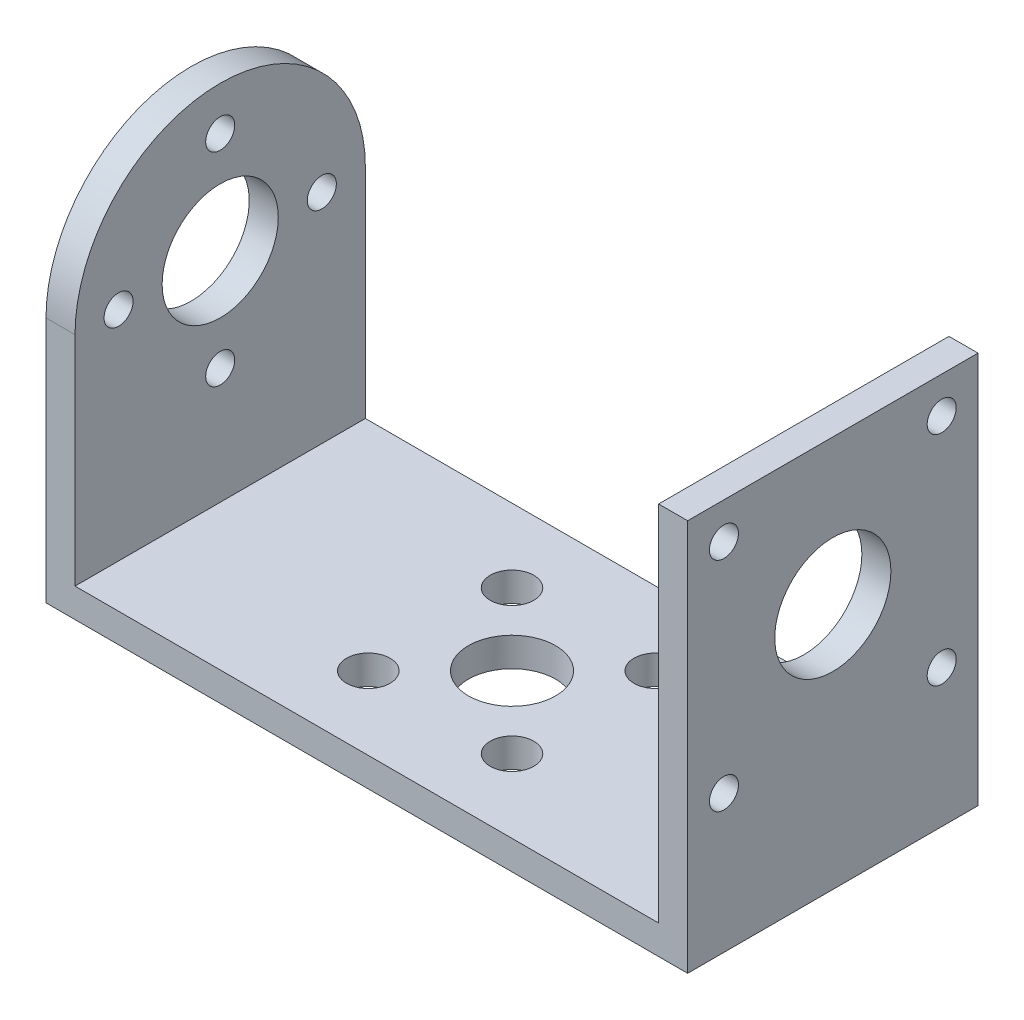
from build123d import *

# Parameters (mm, degrees)
SKETCH_1_W          = 44.2
SKETCH_1_H          = 20
EXTRUDE_1_DEPTH     = 2
CUT_EXTRUDE_1_REACH = 4
SKETCH_2_R          = 3
SKETCH_2_R_2        = 1.5
SKETCH_3_W          = 20
SKETCH_3_H          = 25
EXTRUDE_2_DEPTH     = 2
CUT_EXTRUDE_2_REACH = 46.2
SKETCH_4_R          = 4
SKETCH_4_R_2        = 1
CUT_EXTRUDE_3_REACH = 46.2
SKETCH_5_R          = 4
SKETCH_5_R_2        = 1


with BuildPart() as part:
    # 草图1 → 凸台-拉伸1 (new body)
    with BuildSketch(Plane(origin=(0, 0, 0), x_dir=(1, 0, 0), z_dir=(0, 1, 0))):
        Rectangle(SKETCH_1_W, SKETCH_1_H)
    extrude(amount=EXTRUDE_1_DEPTH)

    # 草图2 → 切除-拉伸1 (cut, up to next)
    with BuildSketch(Plane(origin=(0, 2, 0), x_dir=(1, 0, 0), z_dir=(0, 1, 0)), mode=Mode.PRIVATE) as cut_extrude_1_sk1:
        Circle(SKETCH_2_R)
    cut_extrude_1_tool1 = extrude(cut_extrude_1_sk1.sketch, amount=-CUT_EXTRUDE_1_REACH, mode=Mode.PRIVATE) & part.part
    add(cut_extrude_1_tool1.solids().sort_by_distance((0, 2, 0))[0], mode=Mode.SUBTRACT)
    # 草图2 → 切除-拉伸1 (cut, up to next)
    with BuildSketch(Plane(origin=(0, 2, 0), x_dir=(1, 0, 0), z_dir=(0, 1, 0)), mode=Mode.PRIVATE) as cut_extrude_1_sk2:
        with Locations((4.949747468, -4.949747468)):
            Circle(SKETCH_2_R_2)
    cut_extrude_1_tool2 = extrude(cut_extrude_1_sk2.sketch, amount=-CUT_EXTRUDE_1_REACH, mode=Mode.PRIVATE) & part.part
    add(cut_extrude_1_tool2.solids().sort_by_distance((4.949747, 2, 4.949747))[0], mode=Mode.SUBTRACT)
    # 草图2 → 切除-拉伸1 (cut, up to next)
    with BuildSketch(Plane(origin=(0, 2, 0), x_dir=(1, 0, 0), z_dir=(0, 1, 0)), mode=Mode.PRIVATE) as cut_extrude_1_sk3:
        with Locations((-4.949747468, -4.949747468)):
            Circle(SKETCH_2_R_2)
    cut_extrude_1_tool3 = extrude(cut_extrude_1_sk3.sketch, amount=-CUT_EXTRUDE_1_REACH, mode=Mode.PRIVATE) & part.part
    add(cut_extrude_1_tool3.solids().sort_by_distance((-4.949747, 2, 4.949747))[0], mode=Mode.SUBTRACT)
    # 草图2 → 切除-拉伸1 (cut, up to next)
    with BuildSketch(Plane(origin=(0, 2, 0), x_dir=(1, 0, 0), z_dir=(0, 1, 0)), mode=Mode.PRIVATE) as cut_extrude_1_sk4:
        with Locations((-4.949747468, 4.949747468)):
            Circle(SKETCH_2_R_2)
    cut_extrude_1_tool4 = extrude(cut_extrude_1_sk4.sketch, amount=-CUT_EXTRUDE_1_REACH, mode=Mode.PRIVATE) & part.part
    add(cut_extrude_1_tool4.solids().sort_by_distance((-4.949747, 2, -4.949747))[0], mode=Mode.SUBTRACT)
    # 草图2 → 切除-拉伸1 (cut, up to next)
    with BuildSketch(Plane(origin=(0, 2, 0), x_dir=(1, 0, 0), z_dir=(0, 1, 0)), mode=Mode.PRIVATE) as cut_extrude_1_sk5:
        with Locations((4.949747468, 4.949747468)):
            Circle(SKETCH_2_R_2)
    cut_extrude_1_tool5 = extrude(cut_extrude_1_sk5.sketch, amount=-CUT_EXTRUDE_1_REACH, mode=Mode.PRIVATE) & part.part
    add(cut_extrude_1_tool5.solids().sort_by_distance((4.949747, 2, -4.949747))[0], mode=Mode.SUBTRACT)

    # 草图3 → 凸台-拉伸2 (add)
    with BuildSketch(Plane.ZY.offset(22.1)):
        with Locations((0, 14.5)):
            Rectangle(SKETCH_3_W, SKETCH_3_H)
    extrude_2 = extrude(amount=-EXTRUDE_2_DEPTH)

    # 镜向2: 凸台-拉伸2 across plane
    add(extrude_2.mirror(Plane.ZY))

    # 草图4 → 切除-拉伸2 (cut, up to next)
    with BuildSketch(Plane.ZY.offset(22.1), mode=Mode.PRIVATE) as cut_extrude_2_sk1:
        with BuildLine():
            ThreePointArc((-10, 17), (-7.071067806, 24.071067818), (1.6e-08, 27))
            Line((1.6e-08, 27), (-10, 27))
            Line((-10, 27), (-10, 17))
        make_face()
    cut_extrude_2_tool1 = extrude(cut_extrude_2_sk1.sketch, amount=-CUT_EXTRUDE_2_REACH, mode=Mode.PRIVATE) & part.part
    add(cut_extrude_2_tool1.solids().sort_by_distance((-22.1, 24.766321, -7.766321))[0], mode=Mode.SUBTRACT)
    # 草图4 → 切除-拉伸2 (cut, up to next)
    with BuildSketch(Plane.ZY.offset(22.1), mode=Mode.PRIVATE) as cut_extrude_2_sk2:
        with BuildLine():
            Line((10, 17), (10, 27))
            Line((10, 27), (1.6e-08, 27))
            ThreePointArc((1.6e-08, 27), (7.071067818, 24.071067806), (10, 17))
        make_face()
    cut_extrude_2_tool2 = extrude(cut_extrude_2_sk2.sketch, amount=-CUT_EXTRUDE_2_REACH, mode=Mode.PRIVATE) & part.part
    add(cut_extrude_2_tool2.solids().sort_by_distance((-22.1, 24.766321, 7.766321))[0], mode=Mode.SUBTRACT)
    # 草图4 → 切除-拉伸2 (cut, up to next)
    with BuildSketch(Plane.ZY.offset(22.1), mode=Mode.PRIVATE) as cut_extrude_2_sk3:
        with Locations((0, 17)):
            Circle(SKETCH_4_R)
    cut_extrude_2_tool3 = extrude(cut_extrude_2_sk3.sketch, amount=-CUT_EXTRUDE_2_REACH, mode=Mode.PRIVATE) & part.part
    add(cut_extrude_2_tool3.solids().sort_by_distance((-22.1, 17, 0))[0], mode=Mode.SUBTRACT)
    # 草图4 → 切除-拉伸2 (cut, up to next)
    with BuildSketch(Plane.ZY.offset(22.1), mode=Mode.PRIVATE) as cut_extrude_2_sk4:
        with Locations((0, 24)):
            Circle(SKETCH_4_R_2)
    cut_extrude_2_tool4 = extrude(cut_extrude_2_sk4.sketch, amount=-CUT_EXTRUDE_2_REACH, mode=Mode.PRIVATE) & part.part
    add(cut_extrude_2_tool4.solids().sort_by_distance((-22.1, 24, 0))[0], mode=Mode.SUBTRACT)
    # 草图4 → 切除-拉伸2 (cut, up to next)
    with BuildSketch(Plane.ZY.offset(22.1), mode=Mode.PRIVATE) as cut_extrude_2_sk5:
        with Locations((7, 17)):
            Circle(SKETCH_4_R_2)
    cut_extrude_2_tool5 = extrude(cut_extrude_2_sk5.sketch, amount=-CUT_EXTRUDE_2_REACH, mode=Mode.PRIVATE) & part.part
    add(cut_extrude_2_tool5.solids().sort_by_distance((-22.1, 17, 7))[0], mode=Mode.SUBTRACT)
    # 草图4 → 切除-拉伸2 (cut, up to next)
    with BuildSketch(Plane.ZY.offset(22.1), mode=Mode.PRIVATE) as cut_extrude_2_sk6:
        with Locations((0, 10)):
            Circle(SKETCH_4_R_2)
    cut_extrude_2_tool6 = extrude(cut_extrude_2_sk6.sketch, amount=-CUT_EXTRUDE_2_REACH, mode=Mode.PRIVATE) & part.part
    add(cut_extrude_2_tool6.solids().sort_by_distance((-22.1, 10, 0))[0], mode=Mode.SUBTRACT)
    # 草图4 → 切除-拉伸2 (cut, up to next)
    with BuildSketch(Plane.ZY.offset(22.1), mode=Mode.PRIVATE) as cut_extrude_2_sk7:
        with Locations((-7, 17)):
            Circle(SKETCH_4_R_2)
    cut_extrude_2_tool7 = extrude(cut_extrude_2_sk7.sketch, amount=-CUT_EXTRUDE_2_REACH, mode=Mode.PRIVATE) & part.part
    add(cut_extrude_2_tool7.solids().sort_by_distance((-22.1, 17, -7))[0], mode=Mode.SUBTRACT)

    # 草图5 → 切除-拉伸3 (cut, up to next)
    with BuildSketch(Plane(origin=(22.1, 0, 0), x_dir=(0, 0, -1), z_dir=(1, 0, 0)), mode=Mode.PRIVATE) as cut_extrude_3_sk1:
        with Locations((0, 17)):
            Circle(SKETCH_5_R)
    cut_extrude_3_tool1 = extrude(cut_extrude_3_sk1.sketch, amount=-CUT_EXTRUDE_3_REACH, mode=Mode.PRIVATE) & part.part
    add(cut_extrude_3_tool1.solids().sort_by_distance((22.1, 17, 0))[0], mode=Mode.SUBTRACT)
    # 草图5 → 切除-拉伸3 (cut, up to next)
    with BuildSketch(Plane(origin=(22.1, 0, 0), x_dir=(0, 0, -1), z_dir=(1, 0, 0)), mode=Mode.PRIVATE) as cut_extrude_3_sk2:
        with Locations((-7.5, 24.5)):
            Circle(SKETCH_5_R_2)
    cut_extrude_3_tool2 = extrude(cut_extrude_3_sk2.sketch, amount=-CUT_EXTRUDE_3_REACH, mode=Mode.PRIVATE) & part.part
    add(cut_extrude_3_tool2.solids().sort_by_distance((22.1, 24.5, 7.5))[0], mode=Mode.SUBTRACT)
    # 草图5 → 切除-拉伸3 (cut, up to next)
    with BuildSketch(Plane(origin=(22.1, 0, 0), x_dir=(0, 0, -1), z_dir=(1, 0, 0)), mode=Mode.PRIVATE) as cut_extrude_3_sk3:
        with Locations((7.5, 24.5)):
            Circle(SKETCH_5_R_2)
    cut_extrude_3_tool3 = extrude(cut_extrude_3_sk3.sketch, amount=-CUT_EXTRUDE_3_REACH, mode=Mode.PRIVATE) & part.part
    add(cut_extrude_3_tool3.solids().sort_by_distance((22.1, 24.5, -7.5))[0], mode=Mode.SUBTRACT)
    # 草图5 → 切除-拉伸3 (cut, up to next)
    with BuildSketch(Plane(origin=(22.1, 0, 0), x_dir=(0, 0, -1), z_dir=(1, 0, 0)), mode=Mode.PRIVATE) as cut_extrude_3_sk4:
        with Locations((7.5, 9.5)):
            Circle(SKETCH_5_R_2)
    cut_extrude_3_tool4 = extrude(cut_extrude_3_sk4.sketch, amount=-CUT_EXTRUDE_3_REACH, mode=Mode.PRIVATE) & part.part
    add(cut_extrude_3_tool4.solids().sort_by_distance((22.1, 9.5, -7.5))[0], mode=Mode.SUBTRACT)
    # 草图5 → 切除-拉伸3 (cut, up to next)
    with BuildSketch(Plane(origin=(22.1, 0, 0), x_dir=(0, 0, -1), z_dir=(1, 0, 0)), mode=Mode.PRIVATE) as cut_extrude_3_sk5:
        with Locations((-7.5, 9.5)):
            Circle(SKETCH_5_R_2)
    cut_extrude_3_tool5 = extrude(cut_extrude_3_sk5.sketch, amount=-CUT_EXTRUDE_3_REACH, mode=Mode.PRIVATE) & part.part
    add(cut_extrude_3_tool5.solids().sort_by_distance((22.1, 9.5, 7.5))[0], mode=Mode.SUBTRACT)


solid = part.part
